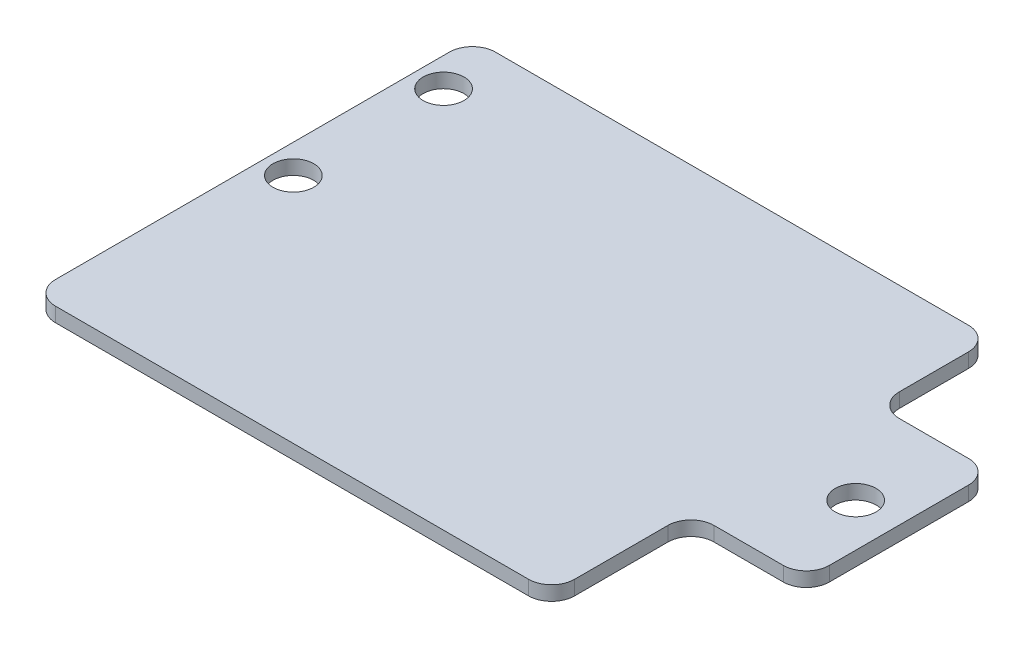
from build123d import *

# Parameters (mm, degrees)
BOSS_EXTRUDE1_DEPTH = 1.5875
FILLET1_R           = 2.54
SKETCH2_R           = 2.2479
CUT_EXTRUDE1_DEPTH  = 2.5875


with BuildPart() as part:
    # Sketch1 → Boss-Extrude1 (new body)
    with BuildSketch(Plane(origin=(0, 0, 0), x_dir=(1, 0, 0), z_dir=(0, 1, 0))):
        Polygon((0, 0), (0, -48.432260883), (57.15, -48.432260883), (57.15, -33.090501198), (69.85, -33.090501198), (69.85, -12.7), (57.15, -12.7), (57.15, 0), align=None)
    extrude(amount=BOSS_EXTRUDE1_DEPTH)

    # Fillet1
    fillet1_edges = [part.edges().sort_by_distance(p)[0] for p in [
        (57.15, 0.79375, 0),
        (57.15, 0.79375, 12.7),
        (69.85, 0.79375, 12.7),
        (69.85, 0.79375, 33.090501198),
        (57.15, 0.79375, 33.090501198),
        (57.15, 0.79375, 48.432260883),
        (0, 0.79375, 48.432260883),
        (0, 0.79375, 0),
    ]]
    fillet(fillet1_edges, radius=FILLET1_R)

    # Sketch2 → Cut-Extrude1 (cut, through all)
    with BuildSketch(Plane(origin=(0, 1.5875, 0), x_dir=(1, 0, 0), z_dir=(0, 1, 0))):
        with Locations((3.175, -6.35)):
            Circle(SKETCH2_R)
        with Locations((3.175, -22.8854)):
            Circle(SKETCH2_R)
        with Locations((65.0748, -22.8854)):
            Circle(SKETCH2_R)
    extrude(amount=-CUT_EXTRUDE1_DEPTH, mode=Mode.SUBTRACT)


solid = part.part
